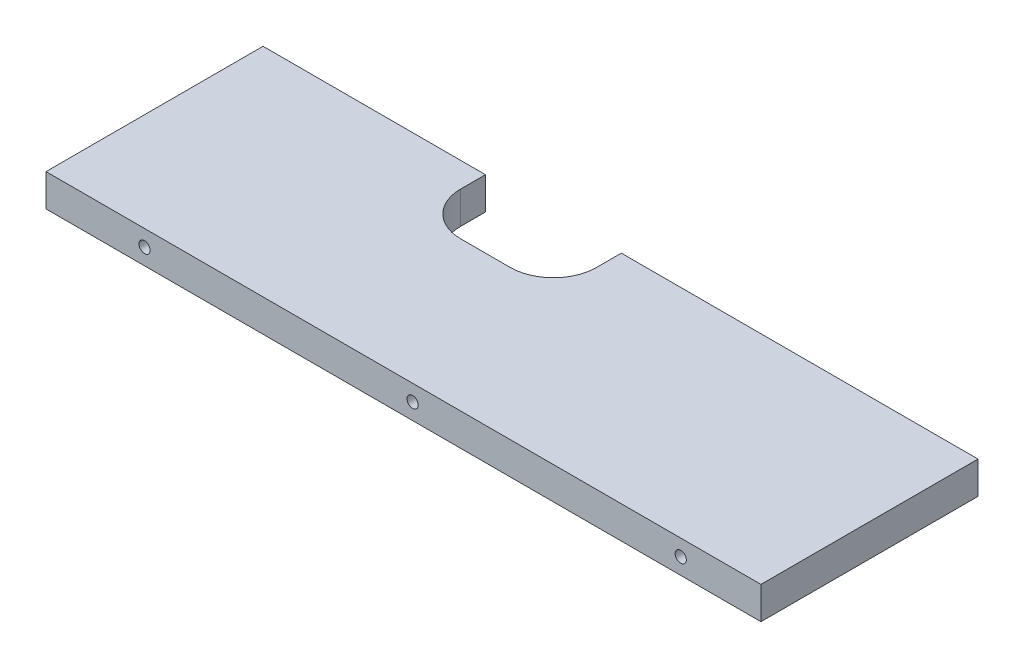
from build123d import *

# Parameters (mm, degrees)
SKETCH1_W                   = 210.475
SKETCH1_H                   = 9.525
BOSS_EXTRUDE1_DEPTH         = 63.9
SKETCH2_W                   = 40
SKETCH2_H                   = 20
CUT_EXTRUDE1_DEPTH          = 10.525
FILLET1_R                   = 12.7
TAP_DRILL_FOR_M4_TAP1_D     = 3.3
TAP_DRILL_FOR_M4_TAP1_DEPTH = 12.7
TAP_DRILL_FOR_M4_TAP1_TIP   = 0.991420021


with BuildPart() as part:
    # Sketch1 → Boss-Extrude1 (new body)
    with BuildSketch(Plane.XY):
        Rectangle(SKETCH1_W, SKETCH1_H)
    extrude(amount=BOSS_EXTRUDE1_DEPTH)

    # Sketch2 → Cut-Extrude1 (cut, through all)
    with BuildSketch(Plane(origin=(0, 4.7625, 0), x_dir=(1, 0, 0), z_dir=(0, 1, 0))):
        with Locations((-19.7625, -10)):
            Rectangle(SKETCH2_W, SKETCH2_H)
    extrude(amount=-CUT_EXTRUDE1_DEPTH, mode=Mode.SUBTRACT)

    # Fillet1
    fillet1_edges = [part.edges().sort_by_distance(p)[0] for p in [
        (-39.7625, 0, 20),
        (0.2375, 0, 20),
    ]]
    fillet(fillet1_edges, radius=FILLET1_R)

    # Tap Drill for M4 Tap1
    with Locations(Plane.XY.offset(63.9)):
        with Locations((-76.2285, 0), (2.6995, 0), (81.6285, 0)):
            Hole(TAP_DRILL_FOR_M4_TAP1_D / 2, depth=TAP_DRILL_FOR_M4_TAP1_DEPTH)
            with Locations((0, 0, -(TAP_DRILL_FOR_M4_TAP1_DEPTH + TAP_DRILL_FOR_M4_TAP1_TIP / 2))):  # 118° drill point
                Cone(0, TAP_DRILL_FOR_M4_TAP1_D / 2, TAP_DRILL_FOR_M4_TAP1_TIP, mode=Mode.SUBTRACT)


solid = part.part
